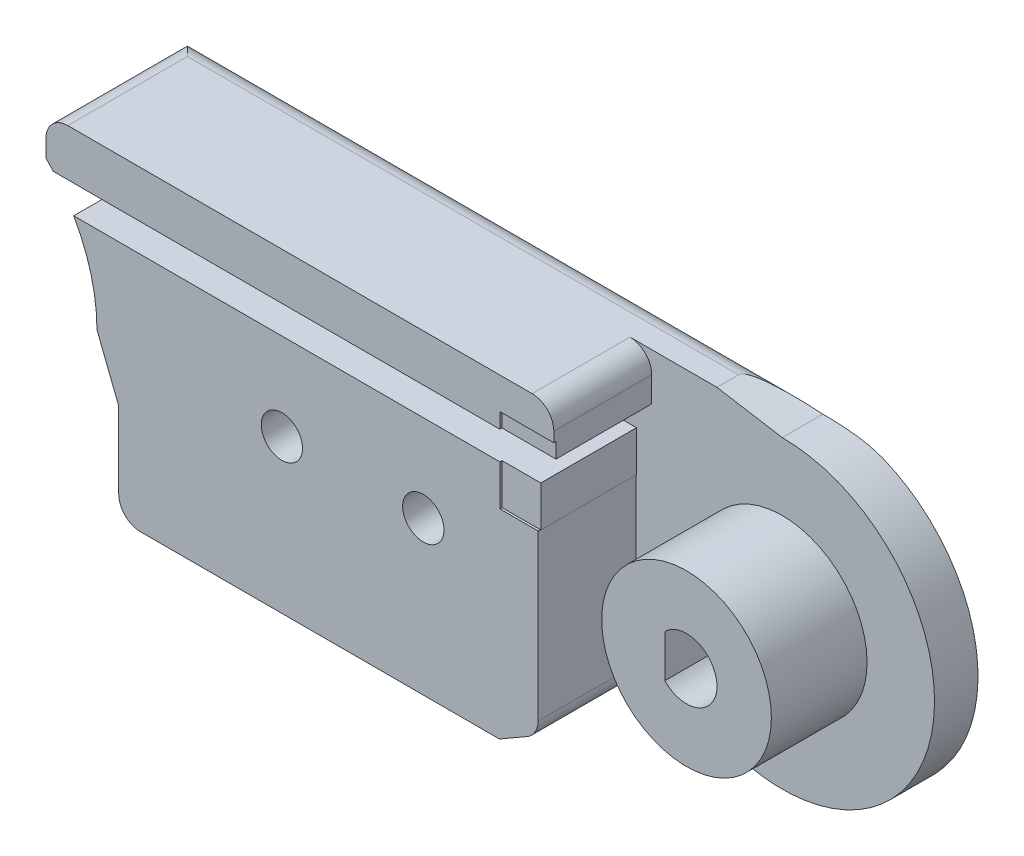
from build123d import *

# Parameters (mm, degrees)
BOSS_EXTRUDE1_DEPTH  = 2
BOSS_EXTRUDE6_DEPTH  = 4.5
CUT_EXTRUDE6_DEPTH   = 4.5
BOSS_EXTRUDE14_DEPTH = 2.3
SKETCH32_R           = 3
CUT_EXTRUDE7_DEPTH   = 2.3
SKETCH33_W           = 22.343119157
SKETCH33_H           = 2
SKETCH33_W_2         = 17.499973406
SKETCH33_H_2         = 1.5
BOSS_EXTRUDE15_DEPTH = 1.2
SKETCH35_W           = 5.479645996
SKETCH35_H           = 3.871139505
CUT_EXTRUDE8_DEPTH   = 2.4
SKETCH36_W           = 3.7
SKETCH36_H           = 1.871139505
CUT_EXTRUDE9_DEPTH   = 4.4
SKETCH37_R           = 3.9
BOSS_EXTRUDE16_DEPTH = 4.4
CUT_EXTRUDE10_DEPTH  = 7.4
SKETCH43_R           = 2.5
BOSS_EXTRUDE17_DEPTH = 1.2
SKETCH44_R           = 0.95
CUT_EXTRUDE11_DEPTH  = 11
SKETCH45_R           = 2
CUT_EXTRUDE12_DEPTH  = 4.5
SKETCH49_R           = 0.75
CUT_EXTRUDE13_DEPTH  = 3
SKETCH51_W           = 3
SKETCH51_H           = 3.965585241
CUT_EXTRUDE14_DEPTH  = 6.8
FILLET1_R            = 1.5
FILLET3_R            = 1


with BuildPart() as part:
    # Sketch3 → Boss-Extrude1 (new body)
    with BuildSketch(Plane.XY):
        with BuildLine():
            Line((8, 0), (9, -2.543145751))
            Line((9, -2.543145751), (9, -7.043145751))
            Line((9, -7.043145751), (26.499973406, -7.043145751))
            Line((26.499973406, -7.043145751), (30.050225938, -4.992893219))
            ThreePointArc((30.050225938, -4.992893219), (41.467130134, -2.721929777), (34.999973406, 6.956854249))
            Line((34.999973406, 6.956854249), (31.999973406, 7.456854249))
            Line((31.999973406, 7.456854249), (5.656854249, 7.456854249))
            Line((5.656854249, 7.456854249), (5.656854249, 5.656854249))
            ThreePointArc((5.656854249, 5.656854249), (7.39103626, 3.061467459), (8, 0))
        make_face()
    extrude(amount=BOSS_EXTRUDE1_DEPTH)

    # Sketch22 → Boss-Extrude6 (add)
    with BuildSketch(Plane.XY.offset(2)):
        with BuildLine():
            Line((5.656854249, 7.456854249), (26.499973406, 7.456854249))
            Line((26.499973406, 7.456854249), (31.999973406, 7.456854249))
            Line((31.999973406, 7.456854249), (31.999973406, 2.128860495))
            Line((31.999973406, 2.128860495), (28.275099672, 2.128860495))
            Line((28.275099672, 2.128860495), (28.275099672, -6.018019485))
            Line((28.275099672, -6.018019485), (26.499973406, -7.043145751))
            Line((26.499973406, -7.043145751), (9, -7.043145751))
            Line((9, -7.043145751), (9, -2.543145751))
            Line((9, -2.543145751), (8, 0))
            ThreePointArc((8, 0), (7.39103626, 3.061467459), (5.656854249, 5.656854249))
            Line((5.656854249, 5.656854249), (5.656854249, 7.456854249))
        make_face()
    extrude(amount=BOSS_EXTRUDE6_DEPTH)

    # Sketch26 → Cut-Extrude6 (cut)
    with BuildSketch(Plane.XY.offset(2)):
        Polygon((18.098080448, 5.3), (2.530052458, 5.3), (2.530052458, 4), (18.098080448, 4), (31.999973406, 4), (31.999973406, 5.3), align=None)
    extrude(amount=CUT_EXTRUDE6_DEPTH, mode=Mode.SUBTRACT)


with BuildPart() as body_2:
    # Sketch31 → Boss-Extrude14 (new body)
    with BuildSketch(Plane.XY.offset(6.5)):
        with BuildLine():
            Line((2.432688066, 5.656854249), (0, 5.656854249))
            ThreePointArc((0, 5.656854249), (-5.656854249, 0), (0, -5.656854249))
            Line((0, -5.656854249), (9, -5.656854249))
            Line((9, -5.656854249), (9, -7.043145751))
            Line((9, -7.043145751), (9, -8.543145751))
            Line((9, -8.543145751), (26.499973406, -8.543145751))
            Line((26.499973406, -8.543145751), (26.499973406, -7.043145751))
            Line((26.499973406, -7.043145751), (26.499973406, 2.128860495))
            Line((26.499973406, 2.128860495), (28.275099672, 2.128860495))
            Line((28.275099672, 2.128860495), (31.999973406, 2.128860495))
            Line((31.999973406, 2.128860495), (31.999973406, 7.456854249))
            Line((31.999973406, 7.456854249), (31.999973406, 8.956854249))
            Line((31.999973406, 8.956854249), (5.656854249, 8.956854249))
            Line((5.656854249, 8.956854249), (5.656854249, 7.456854249))
            Line((5.656854249, 7.456854249), (5.656854249, 5.656854249))
            Line((5.656854249, 5.656854249), (2.432688066, 5.656854249))
        make_face()
    extrude(amount=BOSS_EXTRUDE14_DEPTH)

    # Sketch32 → Cut-Extrude7 (cut)
    with BuildSketch(Plane.XY.offset(8.8)):
        Circle(SKETCH32_R)
    extrude(amount=-CUT_EXTRUDE7_DEPTH, mode=Mode.SUBTRACT)

    # Sketch33 → Boss-Extrude15 (add)
    with BuildSketch(Plane.XY.offset(8.8)):
        with Locations((16.828413828, 7.956854249)):
            Rectangle(SKETCH33_W, SKETCH33_H)
        with Locations((17.749986703, -7.793145751)):
            Rectangle(SKETCH33_W_2, SKETCH33_H_2)
        with BuildLine():
            Line((7, -4.156854249), (25.499973406, -4.156854249))
            Line((25.499973406, -4.156854249), (25.499973406, -2.156854249))
            Line((25.499973406, -2.156854249), (7, -2.156854249))
            ThreePointArc((7, -2.156854249), (6, -3.156854249), (7, -4.156854249))
        make_face()
        with BuildLine():
            Line((25.499973406, 2.172006245), (7, 2.172006245))
            ThreePointArc((7, 2.172006245), (6, 3.172006245), (7, 4.172006245))
            Line((7, 4.172006245), (25.499973406, 4.172006245))
            Line((25.499973406, 4.172006245), (25.499973406, 2.172006245))
        make_face()
    extrude(amount=BOSS_EXTRUDE15_DEPTH)


with BuildPart() as cut_extrude8_tool:
    # Sketch35 → Cut-Extrude8 (new body)
    with BuildSketch(Plane.XY.offset(8.8)):
        with Locations((29.260150408, 4.064430247)):
            Rectangle(SKETCH35_W, SKETCH35_H)
    extrude(amount=-CUT_EXTRUDE8_DEPTH)


with BuildPart() as part_1:
    add(part.part)

    # Cut-Extrude8: cut by cut_extrude8_tool
    add(cut_extrude8_tool.part, mode=Mode.SUBTRACT)

    # Sketch36 → Cut-Extrude9 (cut)
    with BuildSketch(Plane.XY.offset(6.4)):
        with Locations((30.149973406, 3.064430247)):
            Rectangle(SKETCH36_W, SKETCH36_H)
    extrude(amount=-CUT_EXTRUDE9_DEPTH, mode=Mode.SUBTRACT)

    # Sketch37 → Boss-Extrude16 (add)
    with BuildSketch(Plane.XY.offset(2)):
        with Locations((34.999973406, -0.043145751)):
            Circle(SKETCH37_R)
    extrude(amount=BOSS_EXTRUDE16_DEPTH)

    # Sketch39 → Cut-Extrude10 (cut, through all)
    with BuildSketch(Plane.XY.offset(6.4)):
        with BuildLine():
            Line((33.999973406, 0.936650147), (33.999973406, -1.022941648))
            ThreePointArc((33.999973406, -1.022941648), (36.399973406, -0.043145751), (33.999973406, 0.936650147))
        make_face()
    extrude(amount=-CUT_EXTRUDE10_DEPTH, mode=Mode.SUBTRACT)


with BuildPart() as body_2_1:
    add(body_2.part)

    # Cut-Extrude8: cut by cut_extrude8_tool
    add(cut_extrude8_tool.part, mode=Mode.SUBTRACT)

    # Sketch43 → Boss-Extrude17 (add)
    with BuildSketch(Plane.XY.offset(8.8)):
        with Locations((16.5, 0)):
            Circle(SKETCH43_R)
        with Locations((23, 0)):
            Circle(SKETCH43_R)
    extrude(amount=BOSS_EXTRUDE17_DEPTH)


with BuildPart() as cut_extrude11_tool:
    # Sketch44 → Cut-Extrude11 (new body, through all)
    with BuildSketch(Plane.XY.offset(10)):
        with Locations((16.5, 0)):
            Circle(SKETCH44_R)
        with Locations((23, 0)):
            Circle(SKETCH44_R)
    extrude(amount=-CUT_EXTRUDE11_DEPTH)


with BuildPart() as part_2:
    add(part_1.part)

    # Cut-Extrude11: cut by cut_extrude11_tool
    add(cut_extrude11_tool.part, mode=Mode.SUBTRACT)

    # Sketch45 → Cut-Extrude12 (cut)
    with BuildSketch(Plane(origin=(0, 0, 0), x_dir=(-1, 0, 0), z_dir=(0, 0, -1))):
        with Locations((-16.5, 0)):
            Circle(SKETCH45_R)
        with Locations((-23, 0)):
            Circle(SKETCH45_R)
    extrude(amount=-CUT_EXTRUDE12_DEPTH, mode=Mode.SUBTRACT)


with BuildPart() as body_2_2:
    add(body_2_1.part)

    # Cut-Extrude11: cut by cut_extrude11_tool
    add(cut_extrude11_tool.part, mode=Mode.SUBTRACT)

    # Sketch49 → Cut-Extrude13 (cut)
    with BuildSketch(Plane.XZ.offset(-6.956854249)):
        with Locations((24.999973406, 10)):
            Circle(SKETCH49_R)
    extrude(amount=-CUT_EXTRUDE13_DEPTH, mode=Mode.SUBTRACT)


with BuildPart() as cut_extrude14_tool:
    # Sketch51 → Cut-Extrude14 (new body)
    with BuildSketch(Plane.XY.offset(8.8)):
        with Locations((30.499973406, 6.974061629)):
            Rectangle(SKETCH51_W, SKETCH51_H)
    extrude(amount=-CUT_EXTRUDE14_DEPTH)


with BuildPart() as part_3:
    add(part_2.part)

    # Cut-Extrude14: cut by cut_extrude14_tool
    add(cut_extrude14_tool.part, mode=Mode.SUBTRACT)

    # Fillet3
    fillet3_edges = [part_3.edges().sort_by_distance(p)[0] for p in [
        (28.275099672, -6.018019485, 4.25),
        (28.999973406, 7.456854249, 4.25),
        (9, -7.043145751, 3.25),
        (5.656854249, 7.456854249, 3.25),
        (17.749986703, -7.043145751, 0),
        (18.828413828, 7.456854249, 0),
    ]]
    fillet(fillet3_edges, radius=FILLET3_R)


with BuildPart() as body_2_3:
    add(body_2_2.part)

    # Cut-Extrude14: cut by cut_extrude14_tool
    add(cut_extrude14_tool.part, mode=Mode.SUBTRACT)

    # Fillet1
    fillet1_edges = [body_2_3.edges().sort_by_distance(p)[0] for p in [
        (17.328413828, 8.956854249, 6.5),
        (17.749986703, -8.543145751, 6.5),
    ]]
    fillet(fillet1_edges, radius=FILLET1_R)


solid = part_3.part
